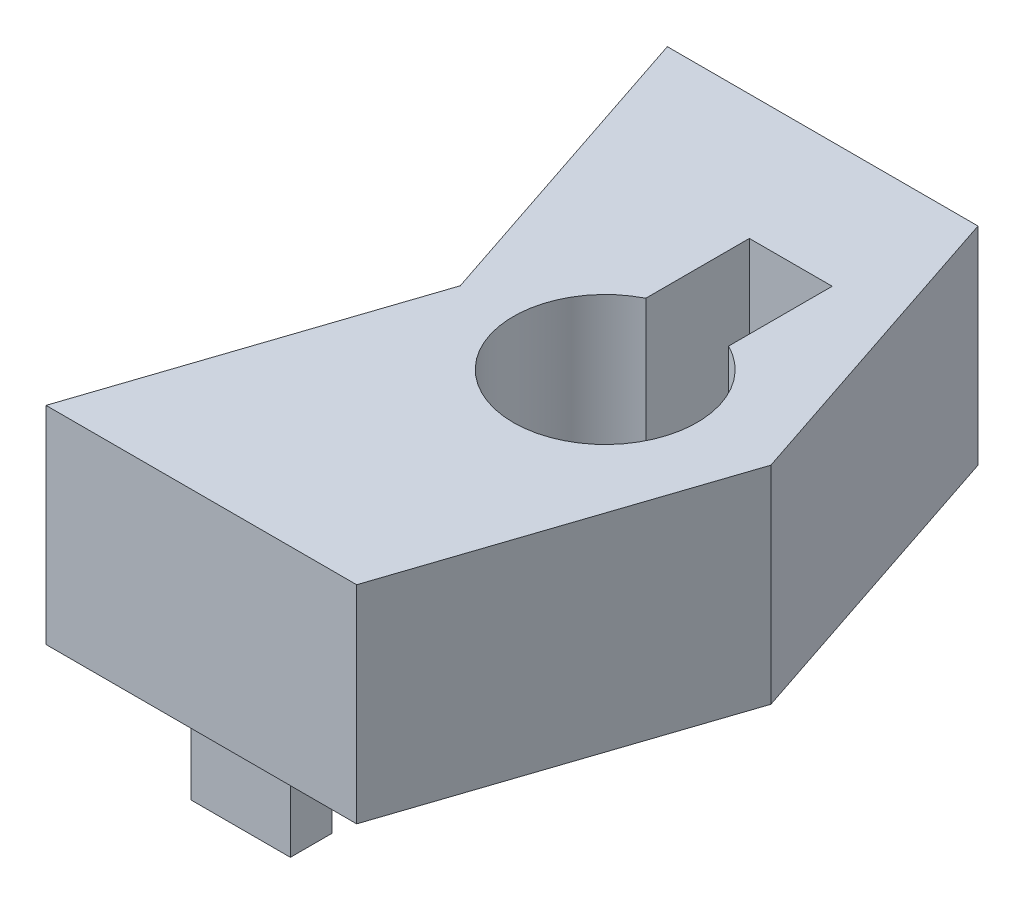
from build123d import *

# Parameters (mm, degrees)
BOSS_EXTRUDE1_DEPTH       = 12.7
SKETCH2_R                 = 5.635000033
HAPTIC_MOTOR_CUTOUT_DEPTH = 9.557999934
SKETCH3_W                 = 5.08
SKETCH3_H                 = 6.35
HAPTIC_WIRE_CUTOUT_DEPTH  = 13.7
SKETCH4_W                 = 6.096
SKETCH4_H                 = 2.54
PINS_DEPTH                = 5.08


with BuildPart() as part:
    # Sketch1 → Boss-Extrude1 (new body)
    with BuildSketch(Plane(origin=(0, 0, 0), x_dir=(1, 0, 0), z_dir=(0, 1, 0))):
        Polygon((0, 0), (19.05, 0), (25.4, 19.05), (19.05, 38.1), (0, 38.1), (6.35, 19.05), align=None)
    extrude(amount=BOSS_EXTRUDE1_DEPTH)

    # Sketch2 → Haptic Motor Cutout (cut)
    with BuildSketch(Plane.XZ.offset(-12.7)):
        with Locations((15.24, -19.05)):
            Circle(SKETCH2_R)
    extrude(amount=HAPTIC_MOTOR_CUTOUT_DEPTH, mode=Mode.SUBTRACT)

    # Sketch3 → Haptic Wire Cutout (cut, through all)
    with BuildSketch(Plane.XZ):
        with Locations((15.24, -27.255072104)):
            Rectangle(SKETCH3_W, SKETCH3_H)
    extrude(amount=-HAPTIC_WIRE_CUTOUT_DEPTH, mode=Mode.SUBTRACT)

    # Sketch4 → Pins (add)
    with BuildSketch(Plane.XZ):
        with Locations((10.668, -35.56)):
            Rectangle(SKETCH4_W, SKETCH4_H)
    pins = extrude(amount=PINS_DEPTH)

    # Mirror1: Pins across plane
    add(pins.mirror(Plane(origin=(0, 0, -19.05), x_dir=(1, 0, 0), z_dir=(0, 0, -1))))


solid = part.part
